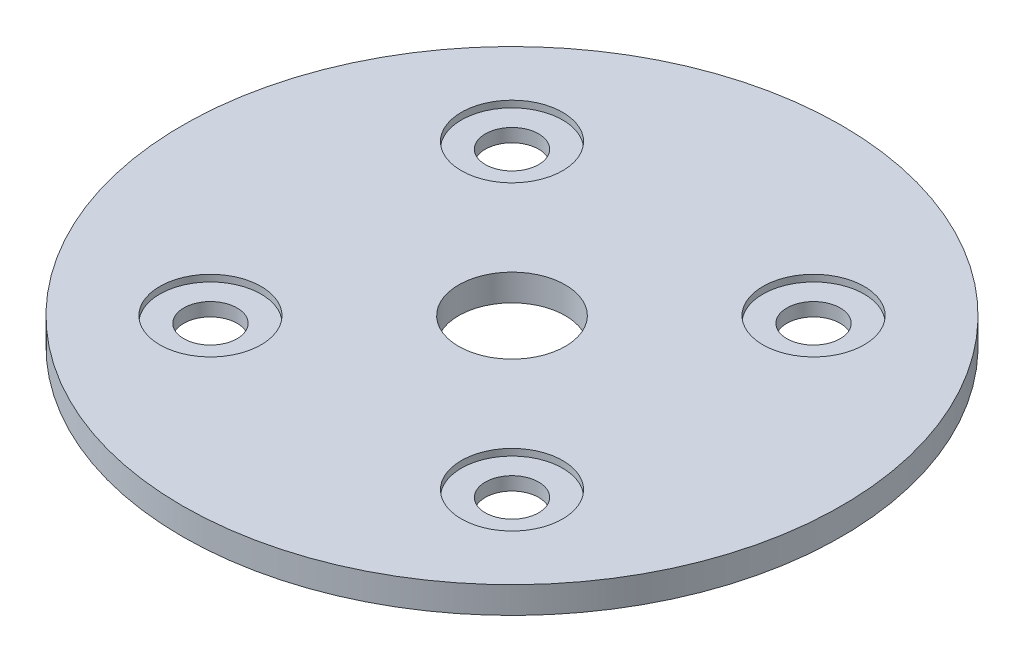
from build123d import *

# Parameters (mm, degrees)
SKETCH2_R                   = 39.2557
BOSS_EXTRUDE1_DEPTH         = 1.5875
F_1_4_0_25_DIAMETER_HOLE1_D = 6.35
F_1_2_0_5_DIAMETER_HOLE1_D  = 12.7
SKETCH10_R                  = 6.0325
CUT_EXTRUDE1_DEPTH          = 0.79375


with BuildPart() as part:
    # Sketch2 → Boss-Extrude1 (new body, symmetric)
    with BuildSketch(Plane(origin=(0, 0, 0), x_dir=(1, 0, 0), z_dir=(0, 1, 0))):
        Circle(SKETCH2_R)
    extrude(amount=BOSS_EXTRUDE1_DEPTH, both=True)

    # 1/4 (0.25) Diameter Hole1 (through all)
    with Locations(Plane(origin=(0, 1.5875, 0), x_dir=(1, 0, 0), z_dir=(0, 1, 0))):
        with Locations((-17.960512242, -17.960512242), (-17.960512242, 17.960512242), (17.960512242, 17.960512242), (17.960512242, -17.960512242)):
            Hole(F_1_4_0_25_DIAMETER_HOLE1_D / 2)

    # 1/2 (0.5) Diameter Hole1 (through all)
    with Locations(Plane(origin=(0, 1.5875, 0), x_dir=(1, 0, 0), z_dir=(0, 1, 0))):
        with Locations((0, 0)):
            Hole(F_1_2_0_5_DIAMETER_HOLE1_D / 2)

    # Sketch10 → Cut-Extrude1 (cut)
    with BuildSketch(Plane(origin=(0, 1.5875, 0), x_dir=(1, 0, 0), z_dir=(0, 1, 0))):
        with Locations((-17.960512242, 17.960512242)):
            Circle(SKETCH10_R)
        with Locations((17.960512242, 17.960512242)):
            Circle(SKETCH10_R)
        with Locations((17.960512242, -17.960512242)):
            Circle(SKETCH10_R)
        with Locations((-17.960512242, -17.960512242)):
            Circle(SKETCH10_R)
    cut_extrude1 = extrude(amount=-CUT_EXTRUDE1_DEPTH, mode=Mode.SUBTRACT)

    # Mirror1: Cut-Extrude1 across plane
    add(cut_extrude1.mirror(Plane.ZX), mode=Mode.SUBTRACT)


solid = part.part
